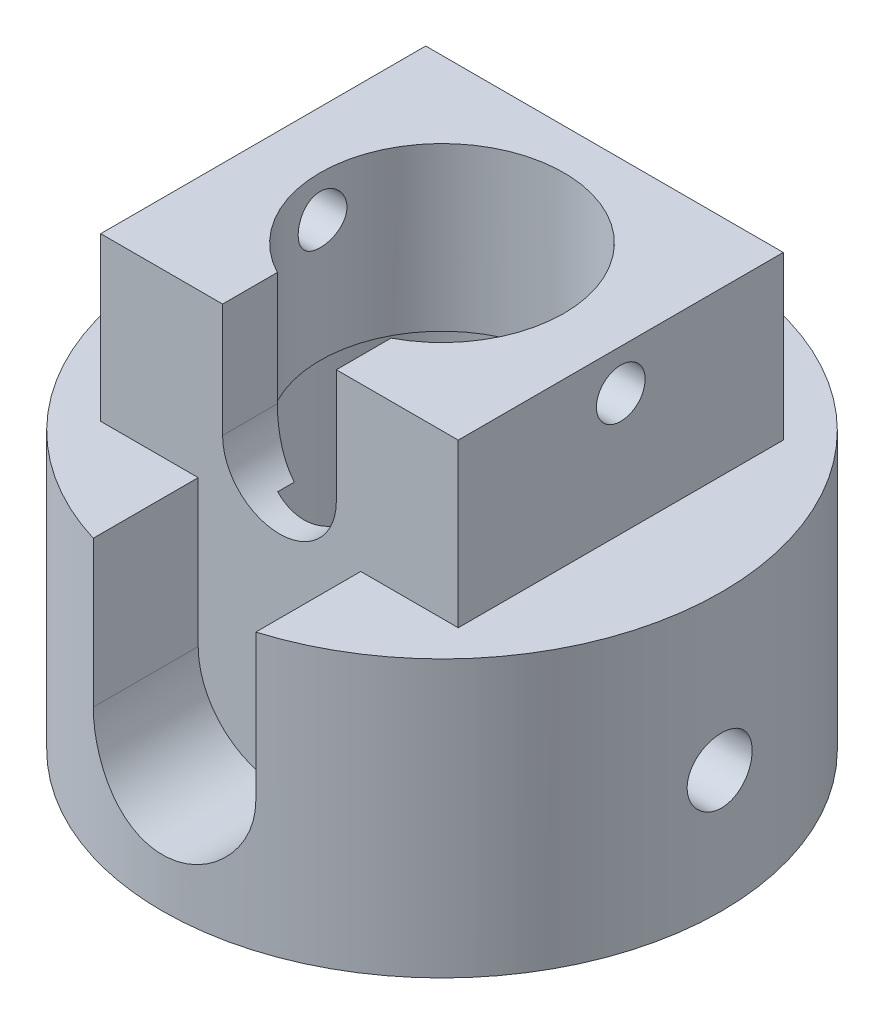
from build123d import *

# Parameters (mm, degrees)
SKETCH1_R           = 17.2
SKETCH1_R_2         = 8.5
BOSS_EXTRUDE1_DEPTH = 17
SKETCH2_W           = 22
SKETCH2_H           = 20
SKETCH2_R           = 7.5
BOSS_EXTRUDE2_DEPTH = 10
SKETCH3_R           = 1.5
CUT_EXTRUDE1_DEPTH  = 22
SKETCH4_R           = 2
CUT_EXTRUDE2_DEPTH  = 20
CUT_EXTRUDE3_DEPTH  = 20
CUT_EXTRUDE4_DEPTH  = 5


with BuildPart() as part:
    # Sketch1 → Boss-Extrude1 (new body)
    with BuildSketch(Plane(origin=(0, 0, 0), x_dir=(1, 0, 0), z_dir=(0, 1, 0))):
        Circle(SKETCH1_R)
        Circle(SKETCH1_R_2, mode=Mode.SUBTRACT)
    extrude(amount=BOSS_EXTRUDE1_DEPTH)

    # Sketch2 → Boss-Extrude2 (add)
    with BuildSketch(Plane(origin=(0, 17, 0), x_dir=(1, 0, 0), z_dir=(0, 1, 0))):
        Rectangle(SKETCH2_W, SKETCH2_H)
        Circle(SKETCH2_R, mode=Mode.SUBTRACT)
    extrude(amount=BOSS_EXTRUDE2_DEPTH)

    # Sketch3 → Cut-Extrude1 (cut)
    with BuildSketch(Plane(origin=(11, 0, 0), x_dir=(0, 0, -1), z_dir=(1, 0, 0))):
        with Locations((0, 24.5)):
            Circle(SKETCH3_R)
    extrude(amount=-CUT_EXTRUDE1_DEPTH, mode=Mode.SUBTRACT)

    # Sketch4 → Cut-Extrude2 (cut)
    with BuildSketch(Plane(origin=(0, 0, 0), x_dir=(0, 0, -1), z_dir=(1, 0, 0))):
        with Locations((0, 7.5)):
            Circle(SKETCH4_R)
    extrude(amount=CUT_EXTRUDE2_DEPTH, mode=Mode.SUBTRACT)

    # Sketch5 → Cut-Extrude3 (cut)
    with BuildSketch(Plane.XY.offset(10)):
        with BuildLine():
            Line((-5, 17), (5, 17))
            Line((5, 17), (5, 8))
            ThreePointArc((5, 8), (0, 3), (-5, 8))
            Line((-5, 8), (-5, 17))
        make_face()
    extrude(amount=CUT_EXTRUDE3_DEPTH, mode=Mode.SUBTRACT)

    # Sketch6 → Cut-Extrude4 (cut)
    with BuildSketch(Plane.XY.offset(10)):
        with BuildLine():
            Line((3.5, 27), (-3.5, 27))
            Line((-3.5, 27), (-3.5, 20))
            ThreePointArc((-3.5, 20), (0, 16.5), (3.5, 20))
            Line((3.5, 20), (3.5, 27))
        make_face()
    extrude(amount=-CUT_EXTRUDE4_DEPTH, mode=Mode.SUBTRACT)


solid = part.part
